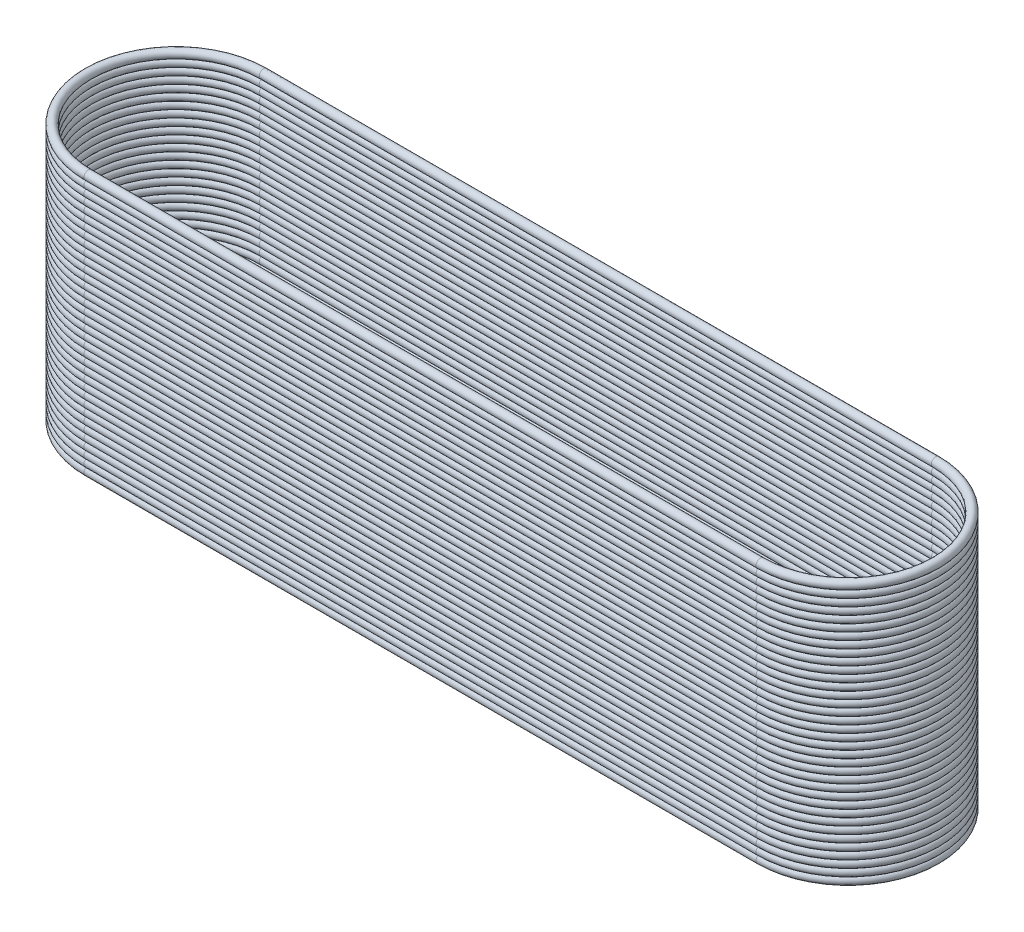
from build123d import *

# Parameters (mm, degrees)
SKETCH2_R       = 0.15
LPATTERN1_COUNT = 36
LPATTERN1_PITCH = 0.25


with BuildPart() as part:
    # Sweep1: sweep along a path in Sketch1
    with BuildLine(Plane(origin=(0, 0, 0), x_dir=(1, 0, 0), z_dir=(0, 1, 0))) as sweep1_path:
        Line((-11.5, 3), (11.5, 3))
        ThreePointArc((11.5, 3), (14.5, 0), (11.5, -3))
        Line((11.5, -3), (-11.5, -3))
        ThreePointArc((-11.5, -3), (-14.5, 0), (-11.5, 3))
    # Sketch2 → Sweep1 (sweep)
    with BuildSketch(Plane(origin=(0, 0, 0), x_dir=(0, 0, -1), z_dir=(1, 0, 0))):
        with Locations((3, 0)):
            Circle(SKETCH2_R)
    sweep1 = sweep(path=sweep1_path.line)

    # LPattern1: Sweep1 ×36
    with Locations(*[(0, i * LPATTERN1_PITCH, 0) for i in range(1, LPATTERN1_COUNT)]):
        add(sweep1)


solid = part.part
